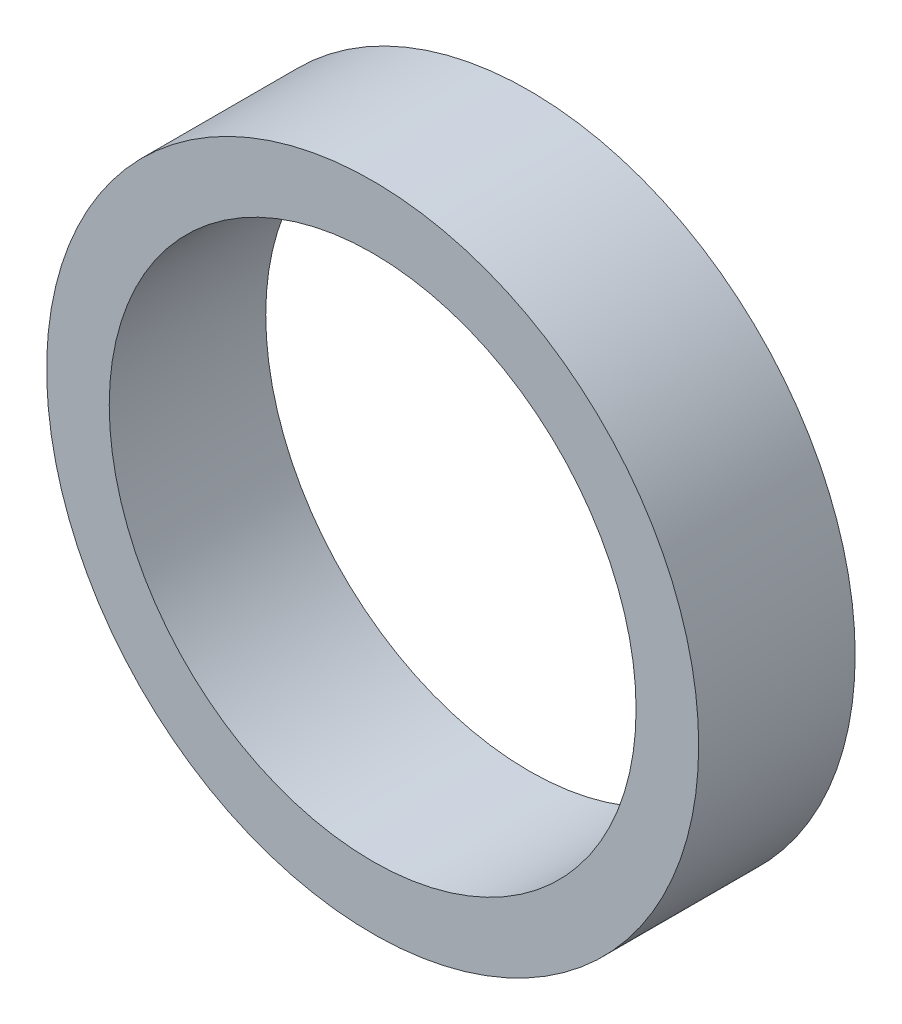
from build123d import *

# Parameters (mm, degrees)
SKETCH_1_R      = 0.75
SKETCH_1_R_2    = 0.606
EXTRUDE_1_DEPTH = 0.36


with BuildPart() as part:
    # Эскиз1 → Бобышка-Вытянуть1 (new body)
    with BuildSketch(Plane.XY):
        Circle(SKETCH_1_R)
        Circle(SKETCH_1_R_2, mode=Mode.SUBTRACT)
    extrude(amount=EXTRUDE_1_DEPTH)


solid = part.part
